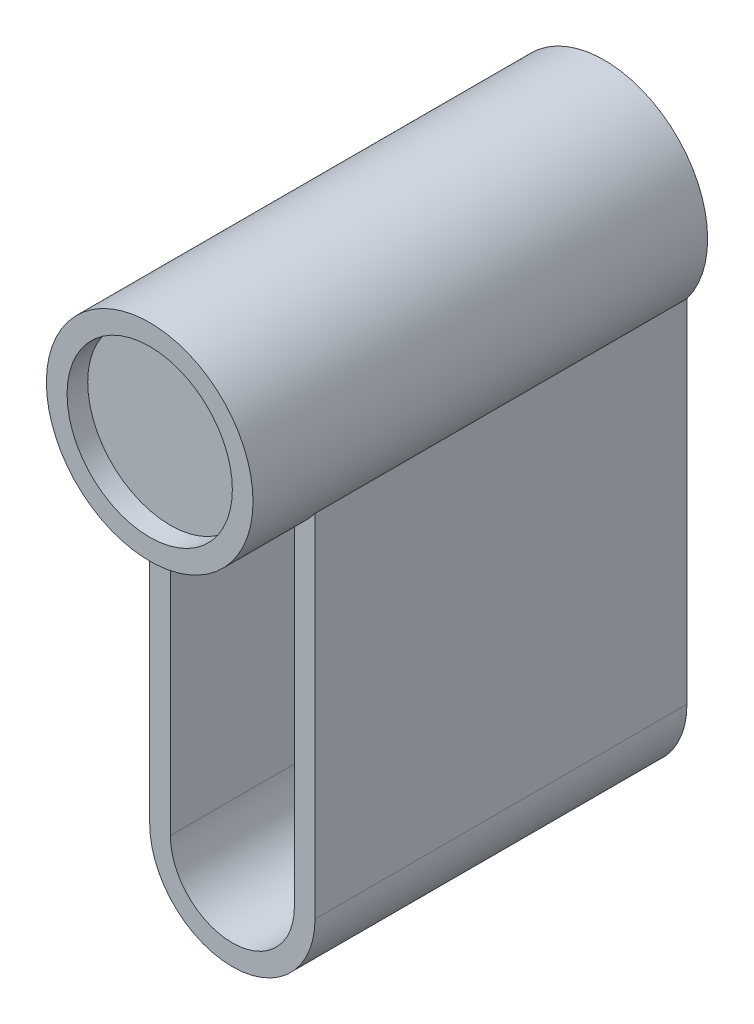
from build123d import *

# Parameters (mm, degrees)
SKETCH1_R      = 25
EXTRUDE1_DEPTH = 110
SKETCH2_R      = 20
EXTRUDE2_DEPTH = 5
EXTRUDE3_DEPTH = 90
EXTRUDE4_DEPTH = 91


with BuildPart() as part:
    # Sketch1 → Extrude1 (new body)
    with BuildSketch(Plane.XY):
        Circle(SKETCH1_R)
    extrude(amount=EXTRUDE1_DEPTH)

    # Sketch2 → Extrude2 (cut)
    with BuildSketch(Plane.XY.offset(110)):
        Circle(SKETCH2_R)
    extrude(amount=-EXTRUDE2_DEPTH, mode=Mode.SUBTRACT)

    # Sketch3 → Extrude3 (add)
    with BuildSketch(Plane.XY):
        with BuildLine():
            Line((-20, -100), (-20, 0))
            Line((-20, 0), (20, 0))
            Line((20, 0), (20, -100))
            ThreePointArc((20, -100), (0, -120), (-20, -100))
        make_face()
    extrude(amount=EXTRUDE3_DEPTH)

    # Sketch4 → Extrude4 (cut, through all)
    with BuildSketch(Plane.XY.offset(90)):
        with BuildLine():
            Line((-15, -20), (-15, -100))
            ThreePointArc((-15, -100), (0, -115), (15, -100))
            Line((15, -100), (15, -20))
            ThreePointArc((15, -20), (0, -25), (-15, -20))
        make_face()
    extrude(amount=-EXTRUDE4_DEPTH, mode=Mode.SUBTRACT)


solid = part.part
